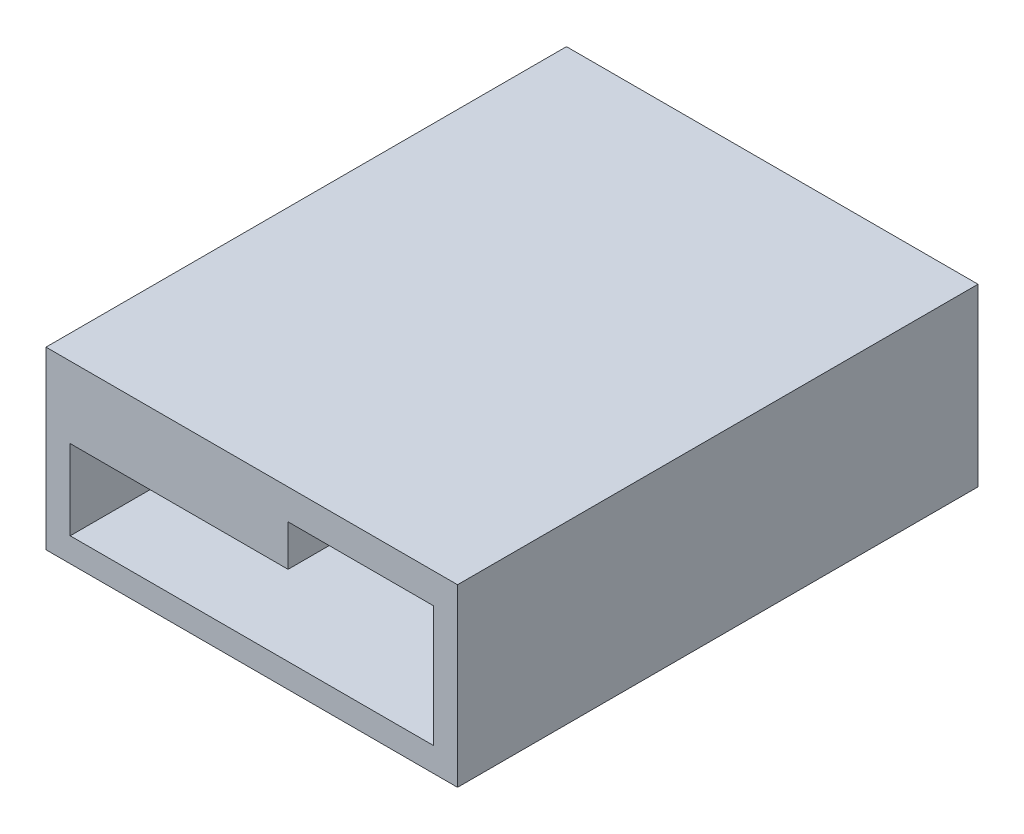
from build123d import *

# Parameters (mm, degrees)
BOSS_EXTRUDE1_DEPTH = 0.4
BOSS_EXTRUDE2_DEPTH = 3
CHAMFER1_SIZE       = 1
SKETCH4_W           = 34
SKETCH4_H           = 43
BOSS_EXTRUDE3_DEPTH = 2.5
BOSS_EXTRUDE4_DEPTH = 10
CUT_EXTRUDE1_REACH  = 7.9
SKETCH6_W           = 22
SKETCH6_H           = 6
SKETCH7_W           = 34
SKETCH7_H           = 43
BOSS_EXTRUDE5_DEPTH = 2


with BuildPart() as part:
    # Sketch2 → Boss-Extrude1 (new body)
    with BuildSketch(Plane(origin=(0, 0, 0), x_dir=(1, 0, 0), z_dir=(0, 1, 0))):
        Polygon((11, 0), (-11, 0), (-11, 6), (-15.5, 6), (-15.5, 47), (9.5, 47), (9.5, 35), (2.5, 35), (2.5, 6), (11, 6), align=None)
    extrude(amount=BOSS_EXTRUDE1_DEPTH)

    # Sketch3 → Boss-Extrude2 (add)
    with BuildSketch(Plane(origin=(0, 0.4, 0), x_dir=(1, 0, 0), z_dir=(0, 1, 0))):
        Polygon((-15.5, 6), (2.5, 6), (2.5, 35), (9.5, 35), (9.5, 47), (-15.5, 47), align=None)
    extrude(amount=BOSS_EXTRUDE2_DEPTH)

    # Chamfer1
    chamfer1_edges = [part.edges().sort_by_distance(p)[0] for p in [
        (11, 0.2, 0),
        (-11, 0.2, 0),
    ]]
    chamfer(chamfer1_edges, length=CHAMFER1_SIZE)

    # Sketch4 → Boss-Extrude3 (add)
    with BuildSketch(Plane(origin=(0, 3.4, 0), x_dir=(1, 0, 0), z_dir=(0, 1, 0))):
        with Locations((-0.5, 27.5)):
            Rectangle(SKETCH4_W, SKETCH4_H)
    extrude(amount=BOSS_EXTRUDE3_DEPTH)

    # Sketch5 → Boss-Extrude4 (add)
    with BuildSketch(Plane.XZ.offset(-3.4)):
        Polygon((-15.5, -6), (-17.5, -6), (-17.5, -49), (16.5, -49), (16.5, -6), (14.5, -6), (14.5, -47), (-15.5, -47), align=None)
    extrude(amount=BOSS_EXTRUDE4_DEPTH)

    # Sketch6 → Cut-Extrude1 (cut, up to next)
    with BuildSketch(Plane.XZ, mode=Mode.PRIVATE) as cut_extrude1_sk1:
        with Locations((0, -3)):
            Rectangle(SKETCH6_W, SKETCH6_H)
    cut_extrude1_tool1 = extrude(cut_extrude1_sk1.sketch, amount=-CUT_EXTRUDE1_REACH, mode=Mode.PRIVATE) & part.part
    add(cut_extrude1_tool1.solids().sort_by_distance((0, 0, -3))[0], mode=Mode.SUBTRACT)

    # Sketch7 → Boss-Extrude5 (add)
    with BuildSketch(Plane.XZ.offset(6.6)):
        with Locations((-0.5, -27.5)):
            Rectangle(SKETCH7_W, SKETCH7_H)
    extrude(amount=BOSS_EXTRUDE5_DEPTH)


solid = part.part
